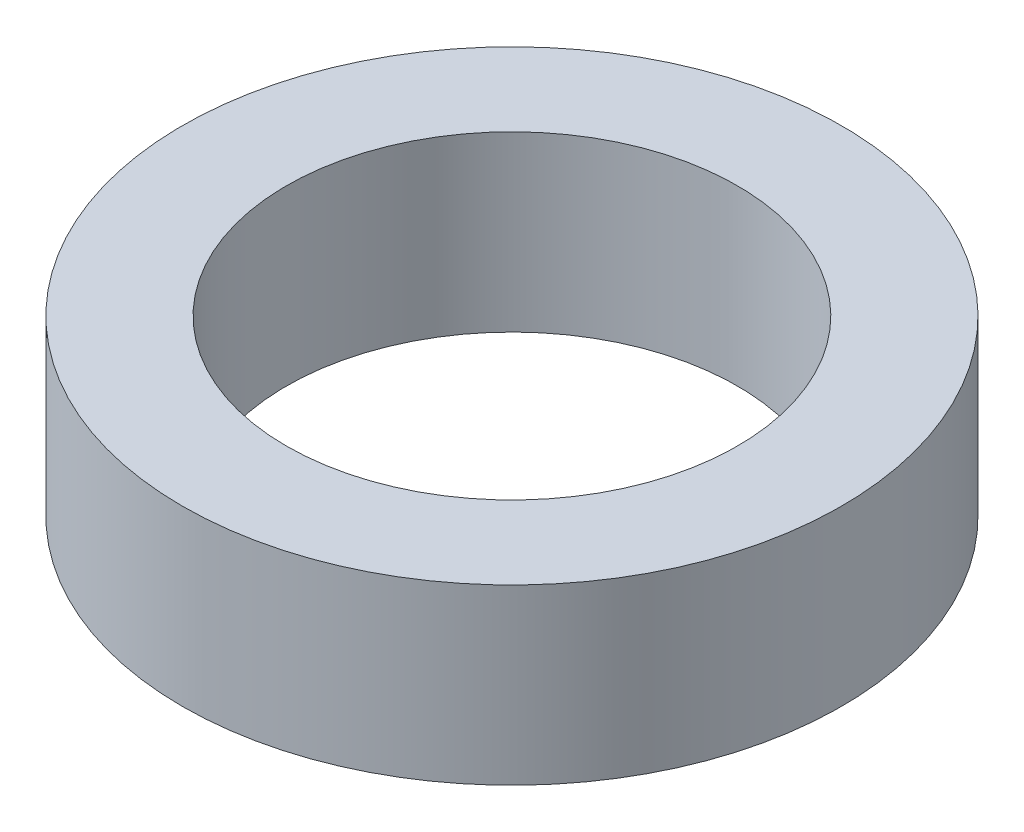
from build123d import *

# Parameters (mm, degrees)
SKETCH1_R           = 12.065
SKETCH1_R_2         = 8.255
BOSS_EXTRUDE1_DEPTH = 6.35


with BuildPart() as part:
    # Sketch1 → Boss-Extrude1 (new body)
    with BuildSketch(Plane(origin=(0, 0, 0), x_dir=(1, 0, 0), z_dir=(0, 1, 0))):
        Circle(SKETCH1_R)
        Circle(SKETCH1_R_2, mode=Mode.SUBTRACT)
    extrude(amount=BOSS_EXTRUDE1_DEPTH)


solid = part.part
